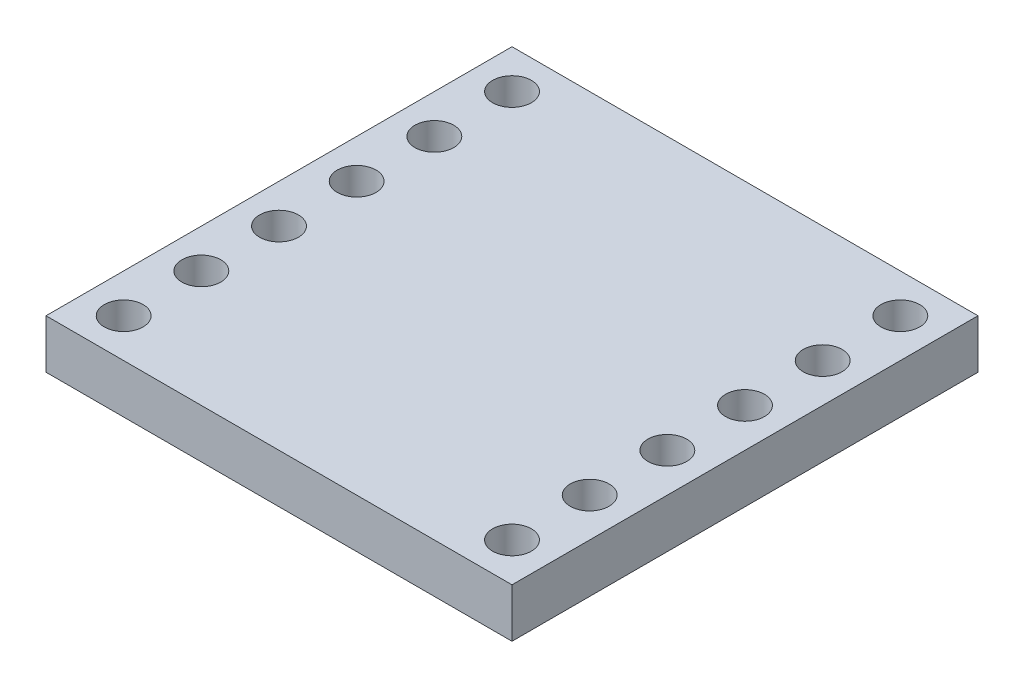
from build123d import *

# Parameters (mm, degrees)
SKETCH1_R           = 0.635
BOSS_EXTRUDE1_DEPTH = 1.6


with BuildPart() as part:
    # Sketch1 → Boss-Extrude1 (new body)
    with BuildSketch(Plane(origin=(0, 0, 0), x_dir=(1, 0, 0), z_dir=(0, 1, 0))):
        Polygon((0, 7.62), (0, -7.62), (-7.62, -7.62), (-7.62, 0), (-7.62, 7.62), align=None)
        with Locations((-6.35, 6.35)):
            Circle(SKETCH1_R, mode=Mode.SUBTRACT)
        with Locations((-6.35, 3.81)):
            Circle(SKETCH1_R, mode=Mode.SUBTRACT)
        with Locations((-6.35, 1.27)):
            Circle(SKETCH1_R, mode=Mode.SUBTRACT)
        with Locations((-6.35, -1.27)):
            Circle(SKETCH1_R, mode=Mode.SUBTRACT)
        with Locations((-6.35, -3.81)):
            Circle(SKETCH1_R, mode=Mode.SUBTRACT)
        with Locations((-6.35, -6.35)):
            Circle(SKETCH1_R, mode=Mode.SUBTRACT)
    boss_extrude1 = extrude(amount=BOSS_EXTRUDE1_DEPTH)

    # Mirror1: Boss-Extrude1 across plane
    add(boss_extrude1.mirror(Plane(origin=(0, 1.6, -7.62), x_dir=(0, 0, 1), z_dir=(-1, 0, 0))))


solid = part.part
